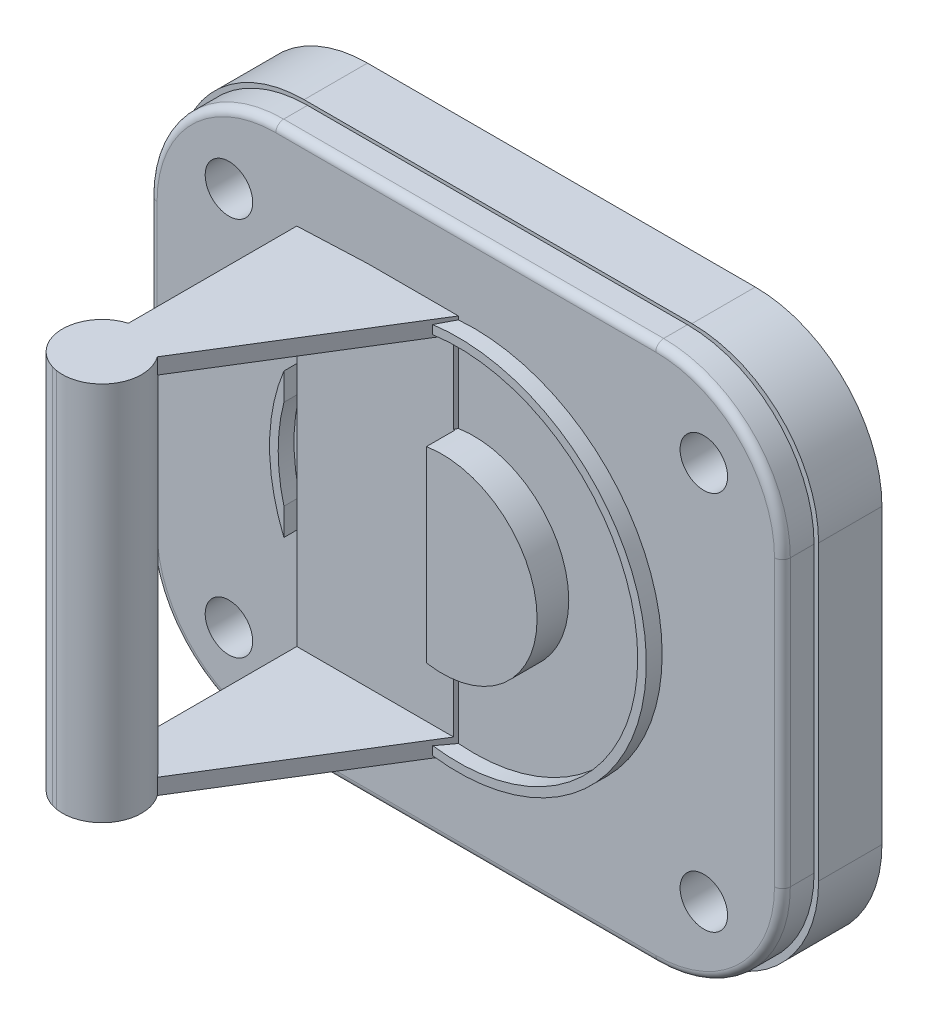
from build123d import *

# Parameters (mm, degrees)
SKETCH3_W            = 40
SKETCH3_H            = 34
SKETCH3_R            = 0.25
SKETCH3_R_2          = 0.5
BOSS_EXTRUDE2_DEPTH  = 2
SKETCH4_R            = 6
BOSS_EXTRUDE3_DEPTH  = 2
SKETCH5_R            = 11.899793619
BOSS_EXTRUDE4_DEPTH  = 1
SKETCH7_R            = 11.354972543
SKETCH7_R_2          = 6
CUT_EXTRUDE1_DEPTH   = 2
BOSS_EXTRUDE5_DEPTH  = 24
SKETCH11_W           = 16
SKETCH11_H           = 22
CUT_EXTRUDE2_DEPTH   = 10
SKETCH12_R           = 2.5
BOSS_EXTRUDE6_DEPTH  = 24
CUT_EXTRUDE3_DEPTH   = 26
FILLET3_R            = 8
FILLET4_R            = 8
FILLET5_R            = 8
FILLET6_R            = 8
SKETCH16_W           = 40.5
SKETCH16_H           = 34.5
BOSS_EXTRUDE12_DEPTH = 4
SKETCH21_R           = 1.5
CUT_EXTRUDE10_DEPTH  = 8
FILLET13_R           = 0.5
FILLET15_R           = 8


with BuildPart() as part:
    # Sketch3 → Boss-Extrude2 (new body)
    with BuildSketch(Plane.XY):
        with Locations((67.033183219, 114.752969631)):
            Rectangle(SKETCH3_W, SKETCH3_H)
        with Locations((82.033183219, 126.752969631)):
            Circle(SKETCH3_R, mode=Mode.SUBTRACT)
        with Locations((52.033183219, 126.752969631)):
            Circle(SKETCH3_R_2, mode=Mode.SUBTRACT)
        with Locations((52.033183219, 102.752969631)):
            Circle(SKETCH3_R, mode=Mode.SUBTRACT)
        with Locations((82.033183219, 102.752969631)):
            Circle(SKETCH3_R_2, mode=Mode.SUBTRACT)
    extrude(amount=BOSS_EXTRUDE2_DEPTH)

    # Sketch4 → Boss-Extrude3 (add)
    with BuildSketch(Plane.XY.offset(2)):
        with Locations((67.537199027, 114.923254134)):
            Circle(SKETCH4_R)
    extrude(amount=BOSS_EXTRUDE3_DEPTH)

    # Sketch5 → Boss-Extrude4 (add)
    with BuildSketch(Plane.XY.offset(2)):
        with Locations((67.537199027, 114.923254134)):
            Circle(SKETCH5_R)
    extrude(amount=BOSS_EXTRUDE4_DEPTH)

    # Sketch7 → Cut-Extrude1 (cut)
    with BuildSketch(Plane.XY.offset(4)):
        with Locations((67.537199027, 114.923254134)):
            Circle(SKETCH7_R)
        with Locations((67.537199027, 114.923254134)):
            Circle(SKETCH7_R_2, mode=Mode.SUBTRACT)
    extrude(amount=-CUT_EXTRUDE1_DEPTH, mode=Mode.SUBTRACT)

    # Sketch10 → Boss-Extrude5 (add)
    with BuildSketch(Plane(origin=(0, 103, 0), x_dir=(1, 0, 0), z_dir=(0, 1, 0))):
        Polygon((66.720095213, -1.747898749), (56.543730993, -18.18677206), (56.543730993, -2.18677206), align=None)
    extrude(amount=BOSS_EXTRUDE5_DEPTH)

    # Sketch11 → Cut-Extrude2 (cut)
    with BuildSketch(Plane.ZY.offset(-56.543730993)):
        with Locations((10.18677206, 115)):
            Rectangle(SKETCH11_W, SKETCH11_H)
    extrude(amount=-CUT_EXTRUDE2_DEPTH, mode=Mode.SUBTRACT)

    # Sketch12 → Boss-Extrude6 (add)
    with BuildSketch(Plane.XZ.offset(-103)):
        with Locations((57.268401618, 15.213410807)):
            Circle(SKETCH12_R)
    extrude(amount=-BOSS_EXTRUDE6_DEPTH)

    # Sketch14 → Cut-Extrude3 (cut)
    with BuildSketch(Plane(origin=(0, 127, 0), x_dir=(1, 0, 0), z_dir=(0, 1, 0))):
        Polygon((56.543730993, -17.606077203), (56.543730993, -18.18677206), (56.857779916, -17.679458215), align=None)
    extrude(amount=-CUT_EXTRUDE3_DEPTH, mode=Mode.SUBTRACT)

    # Fillet3
    fillet3_edges = [part.edges().sort_by_distance(p)[0] for p in [
        (87.033183219, 131.752969631, 1),
    ]]
    fillet(fillet3_edges, radius=FILLET3_R)

    # Fillet4
    fillet4_edges = [part.edges().sort_by_distance(p)[0] for p in [
        (87.033183219, 97.752969631, 1),
    ]]
    fillet(fillet4_edges, radius=FILLET4_R)

    # Fillet5
    fillet5_edges = [part.edges().sort_by_distance(p)[0] for p in [
        (47.033183219, 131.752969631, 1),
    ]]
    fillet(fillet5_edges, radius=FILLET5_R)

    # Fillet6
    fillet6_edges = [part.edges().sort_by_distance(p)[0] for p in [
        (47.033183219, 97.752969631, 1),
    ]]
    fillet(fillet6_edges, radius=FILLET6_R)

    # Sketch16 → Boss-Extrude12 (add)
    with BuildSketch(Plane(origin=(0, 0, 0), x_dir=(-1, 0, 0), z_dir=(0, 0, -1))):
        with Locations((-67.069775125, 114.708699914)):
            Rectangle(SKETCH16_W, SKETCH16_H)
    extrude(amount=BOSS_EXTRUDE12_DEPTH)

    # Sketch21 → Cut-Extrude10 (cut)
    with BuildSketch(Plane(origin=(0, 0, -4), x_dir=(-1, 0, 0), z_dir=(0, 0, -1))):
        with Locations((-82.069775125, 126.708699914)):
            Circle(SKETCH21_R)
        with Locations((-52.069775125, 126.708699914)):
            Circle(SKETCH21_R)
        with Locations((-52.069775125, 102.708699914)):
            Circle(SKETCH21_R)
        with Locations((-82.069775125, 102.708699914)):
            Circle(SKETCH21_R)
    extrude(amount=-CUT_EXTRUDE10_DEPTH, mode=Mode.SUBTRACT)

    # Fillet13
    fillet13_edges = [part.edges().sort_by_distance(p)[0] for p in [
        (67.033183219, 131.752969631, 2),
        (84.690037469, 129.409823881, 2),
        (87.033183219, 114.752969631, 2),
        (84.690037469, 100.096115382, 2),
        (47.033183219, 114.752969631, 2),
        (49.37632897, 129.409823881, 2),
        (67.033183219, 97.752969631, 2),
        (49.37632897, 100.096115382, 2),
    ]]
    fillet(fillet13_edges, radius=FILLET13_R)

    # Fillet15
    fillet15_edges = [part.edges().sort_by_distance(p)[0] for p in [
        (87.319775125, 131.958699914, -2),
        (87.319775125, 97.458699914, -2),
        (46.819775125, 97.458699914, -2),
        (46.819775125, 131.958699914, -2),
    ]]
    fillet(fillet15_edges, radius=FILLET15_R)


solid = part.part
